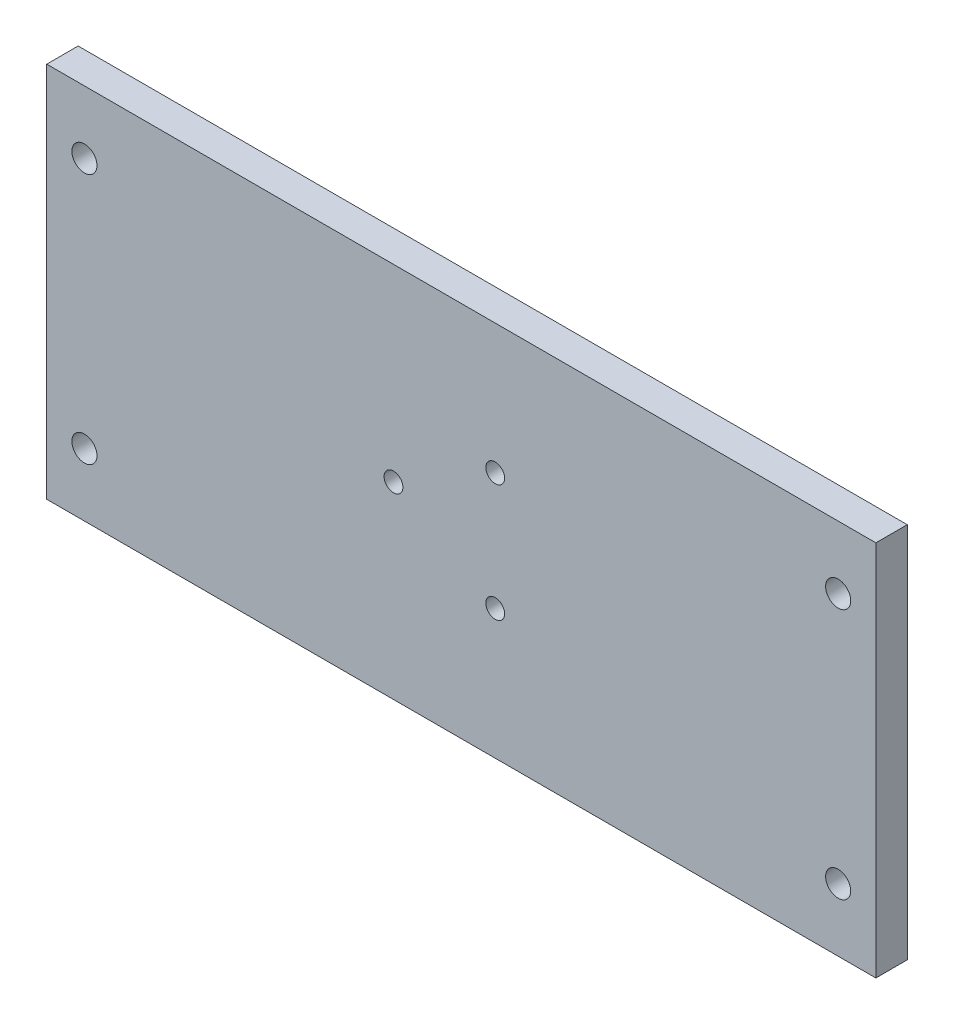
from build123d import *

# Parameters (mm, degrees)
SKETCH1_W           = 140
SKETCH1_H           = 60
BOSS_EXTRUDE1_DEPTH = 5
CUT_EXTRUDE1_REACH  = 7
SKETCH2_R           = 2
SKETCH3_W           = 4
SKETCH3_H           = 60
CUT_EXTRUDE2_DEPTH  = 6
CUT_EXTRUDE3_REACH  = 7
SKETCH4_R           = 1.5


with BuildPart() as part:
    # Sketch1 → Boss-Extrude1 (new body)
    with BuildSketch(Plane.XY):
        Rectangle(SKETCH1_W, SKETCH1_H)
    extrude(amount=BOSS_EXTRUDE1_DEPTH)

    # Sketch2 → Cut-Extrude1 (cut, up to next)
    with BuildSketch(Plane.XY.offset(5), mode=Mode.PRIVATE) as cut_extrude1_sk1:
        with Locations((-60, 20)):
            Circle(SKETCH2_R)
    cut_extrude1_tool1 = extrude(cut_extrude1_sk1.sketch, amount=-CUT_EXTRUDE1_REACH, mode=Mode.PRIVATE) & part.part
    add(cut_extrude1_tool1.solids().sort_by_distance((-60, 20, 5))[0], mode=Mode.SUBTRACT)
    # Sketch2 → Cut-Extrude1 (cut, up to next)
    with BuildSketch(Plane.XY.offset(5), mode=Mode.PRIVATE) as cut_extrude1_sk2:
        with Locations((60, 20)):
            Circle(SKETCH2_R)
    cut_extrude1_tool2 = extrude(cut_extrude1_sk2.sketch, amount=-CUT_EXTRUDE1_REACH, mode=Mode.PRIVATE) & part.part
    add(cut_extrude1_tool2.solids().sort_by_distance((60, 20, 5))[0], mode=Mode.SUBTRACT)
    # Sketch2 → Cut-Extrude1 (cut, up to next)
    with BuildSketch(Plane.XY.offset(5), mode=Mode.PRIVATE) as cut_extrude1_sk3:
        with Locations((60, -20)):
            Circle(SKETCH2_R)
    cut_extrude1_tool3 = extrude(cut_extrude1_sk3.sketch, amount=-CUT_EXTRUDE1_REACH, mode=Mode.PRIVATE) & part.part
    add(cut_extrude1_tool3.solids().sort_by_distance((60, -20, 5))[0], mode=Mode.SUBTRACT)
    # Sketch2 → Cut-Extrude1 (cut, up to next)
    with BuildSketch(Plane.XY.offset(5), mode=Mode.PRIVATE) as cut_extrude1_sk4:
        with Locations((-60, -20)):
            Circle(SKETCH2_R)
    cut_extrude1_tool4 = extrude(cut_extrude1_sk4.sketch, amount=-CUT_EXTRUDE1_REACH, mode=Mode.PRIVATE) & part.part
    add(cut_extrude1_tool4.solids().sort_by_distance((-60, -20, 5))[0], mode=Mode.SUBTRACT)

    # Sketch3 → Cut-Extrude2 (cut, through all)
    with BuildSketch(Plane.XY.offset(5)):
        with Locations((-68, 0)):
            Rectangle(SKETCH3_W, SKETCH3_H)
        with Locations((68, 0)):
            Rectangle(SKETCH3_W, SKETCH3_H)
    extrude(amount=-CUT_EXTRUDE2_DEPTH, mode=Mode.SUBTRACT)

    # Sketch4 → Cut-Extrude3 (cut, up to next)
    with BuildSketch(Plane.XY.offset(5), mode=Mode.PRIVATE) as cut_extrude3_sk1:
        with Locations((5.3975, 9.348744234)):
            Circle(SKETCH4_R)
    cut_extrude3_tool1 = extrude(cut_extrude3_sk1.sketch, amount=-CUT_EXTRUDE3_REACH, mode=Mode.PRIVATE) & part.part
    add(cut_extrude3_tool1.solids().sort_by_distance((5.3975, 9.348744, 5))[0], mode=Mode.SUBTRACT)
    # Sketch4 → Cut-Extrude3 (cut, up to next)
    with BuildSketch(Plane.XY.offset(5), mode=Mode.PRIVATE) as cut_extrude3_sk2:
        with Locations((5.3975, -9.348744234)):
            Circle(SKETCH4_R)
    cut_extrude3_tool2 = extrude(cut_extrude3_sk2.sketch, amount=-CUT_EXTRUDE3_REACH, mode=Mode.PRIVATE) & part.part
    add(cut_extrude3_tool2.solids().sort_by_distance((5.3975, -9.348744, 5))[0], mode=Mode.SUBTRACT)
    # Sketch4 → Cut-Extrude3 (cut, up to next)
    with BuildSketch(Plane.XY.offset(5), mode=Mode.PRIVATE) as cut_extrude3_sk3:
        with Locations((-10.795, 0)):
            Circle(SKETCH4_R)
    cut_extrude3_tool3 = extrude(cut_extrude3_sk3.sketch, amount=-CUT_EXTRUDE3_REACH, mode=Mode.PRIVATE) & part.part
    add(cut_extrude3_tool3.solids().sort_by_distance((-10.795, 0, 5))[0], mode=Mode.SUBTRACT)


solid = part.part
